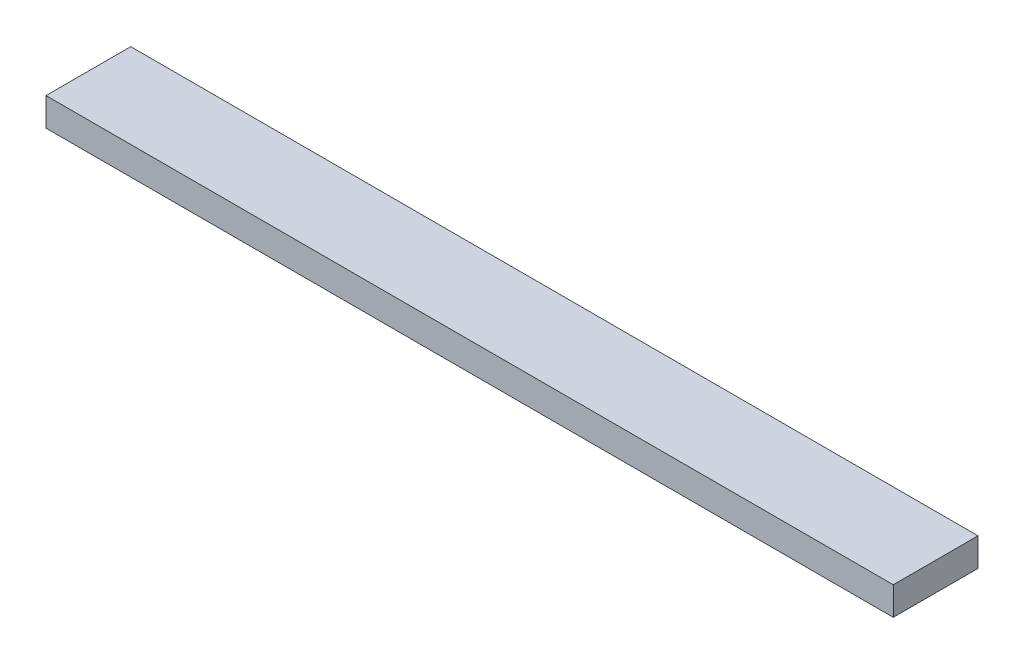
from build123d import *

# Parameters (mm, degrees)
SKETCH1_W           = 300
SKETCH1_H           = 30
BOSS_EXTRUDE1_DEPTH = 10


with BuildPart() as part:
    # Sketch1 → Boss-Extrude1 (new body)
    with BuildSketch(Plane(origin=(0, 0, 0), x_dir=(1, 0, 0), z_dir=(0, 1, 0))):
        Rectangle(SKETCH1_W, SKETCH1_H)
    extrude(amount=BOSS_EXTRUDE1_DEPTH)


solid = part.part
